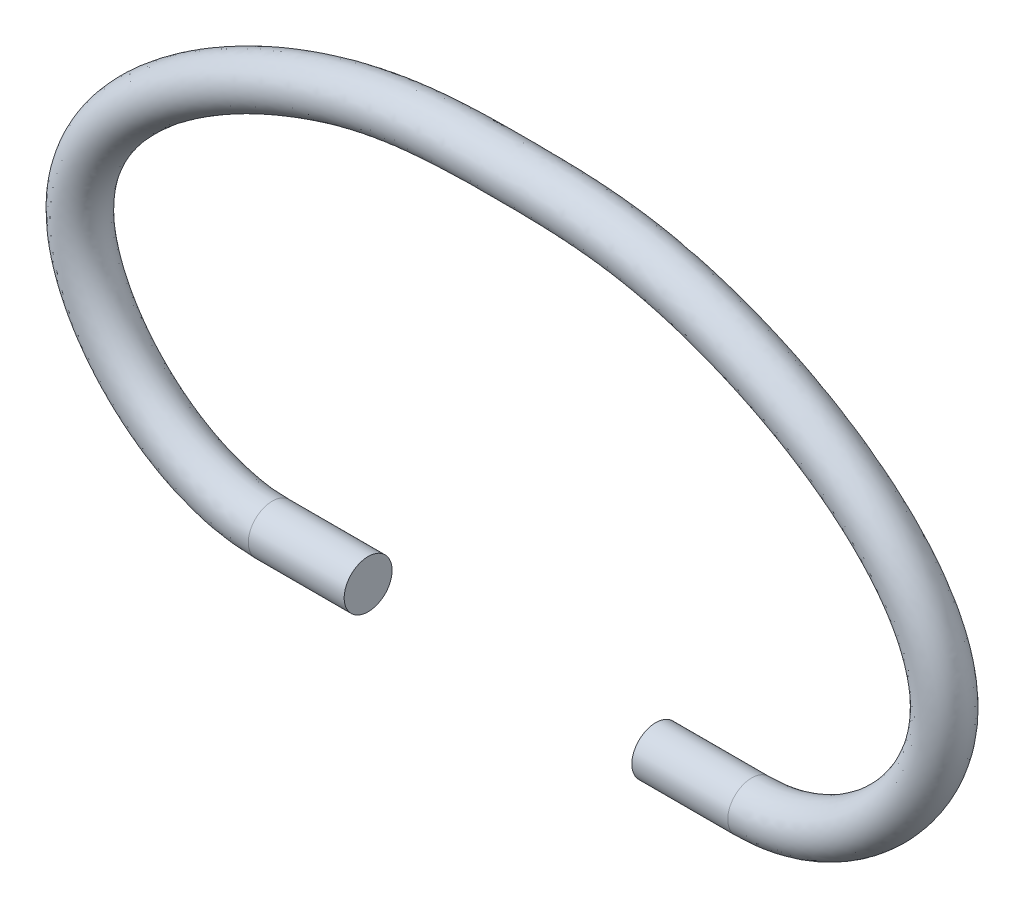
from build123d import *

# Parameters (mm, degrees)
CROQUIS2_R = 0.5


with BuildPart() as part:
    # Barrer1: sweep along a path in Croquis1
    with BuildLine(Plane.XY) as barrer1_path:
        Line((-3, 0), (-5, 0))
        add(Edge.make_bspline(
            [(-5, 0), (-7.005238436, 0), (-11.559503465, 4.580656152), (-4.507053739, 8.937842035), (0.000221656, 9.01703725), (4.505436377, 8.937842035), (11.5729986, 4.580656152), (6.986723122, 0), (5, 0)],
            knots=[0, 0, 0, 0, 0.163058244, 0.40764561, 0.5, 0.59235439, 0.836941756, 1, 1, 1, 1], degree=3))
        Line((5, 0), (3, 0))
    # Croquis2 → Barrer1 (sweep)
    with BuildSketch(Plane(origin=(3, 0, 0), x_dir=(0, 0, -1), z_dir=(1, 0, 0))):
        Circle(CROQUIS2_R)
    sweep(path=barrer1_path.line)


solid = part.part
